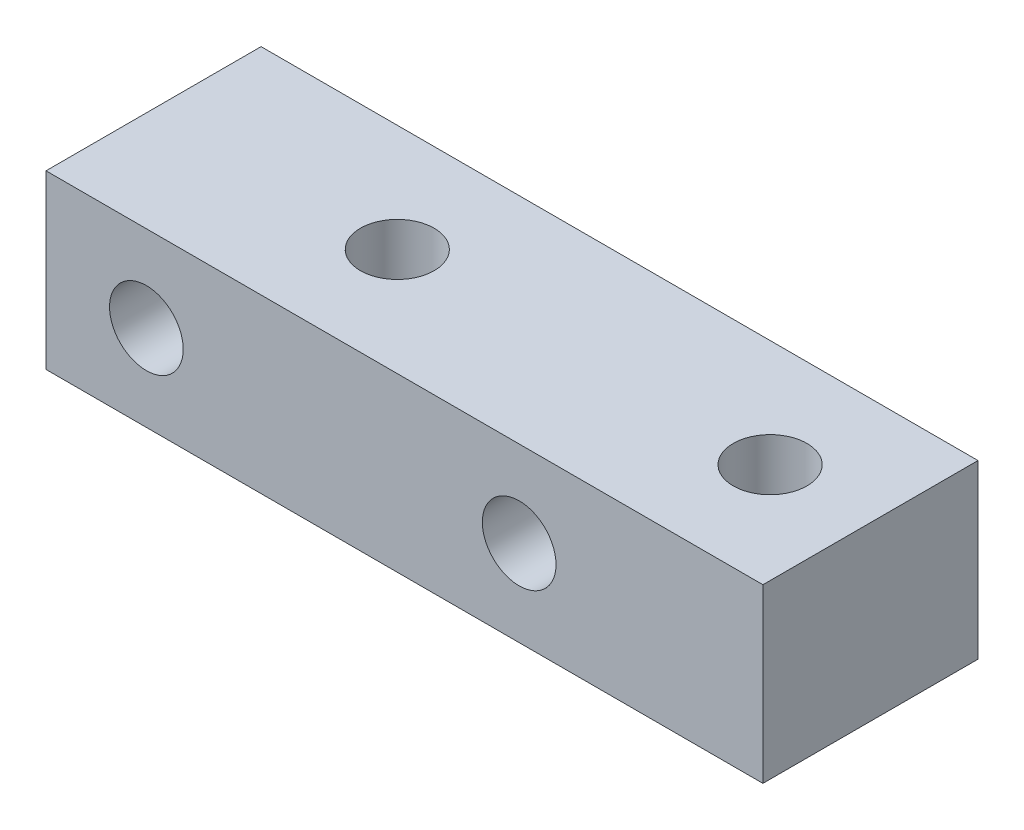
from build123d import *

# Parameters (mm, degrees)
SKETCH2_W               = 63.5
SKETCH2_H               = 19.05
BOSS_EXTRUDE1_DEPTH     = 15.24
F_1_4_CLEARANCE_HOLE2_D = 6.5278
F_1_4_CLEARANCE_HOLE3_D = 6.5278


with BuildPart() as part:
    # Sketch2 → Boss-Extrude1 (new body)
    with BuildSketch(Plane(origin=(0, 0, 0), x_dir=(1, 0, 0), z_dir=(0, 1, 0))):
        Rectangle(SKETCH2_W, SKETCH2_H)
    extrude(amount=-BOSS_EXTRUDE1_DEPTH)

    # 1/4 Clearance Hole2 (through all)
    with Locations(Plane.XY.offset(9.525)):
        with Locations((-22.86, -7.62), (10.16, -7.62)):
            Hole(F_1_4_CLEARANCE_HOLE2_D / 2)

    # 1/4 Clearance Hole3 (through all)
    with Locations(Plane(origin=(0, 0, 0), x_dir=(1, 0, 0), z_dir=(0, 1, 0))):
        with Locations((-10.16, 0), (22.86, 0)):
            Hole(F_1_4_CLEARANCE_HOLE3_D / 2)


solid = part.part
